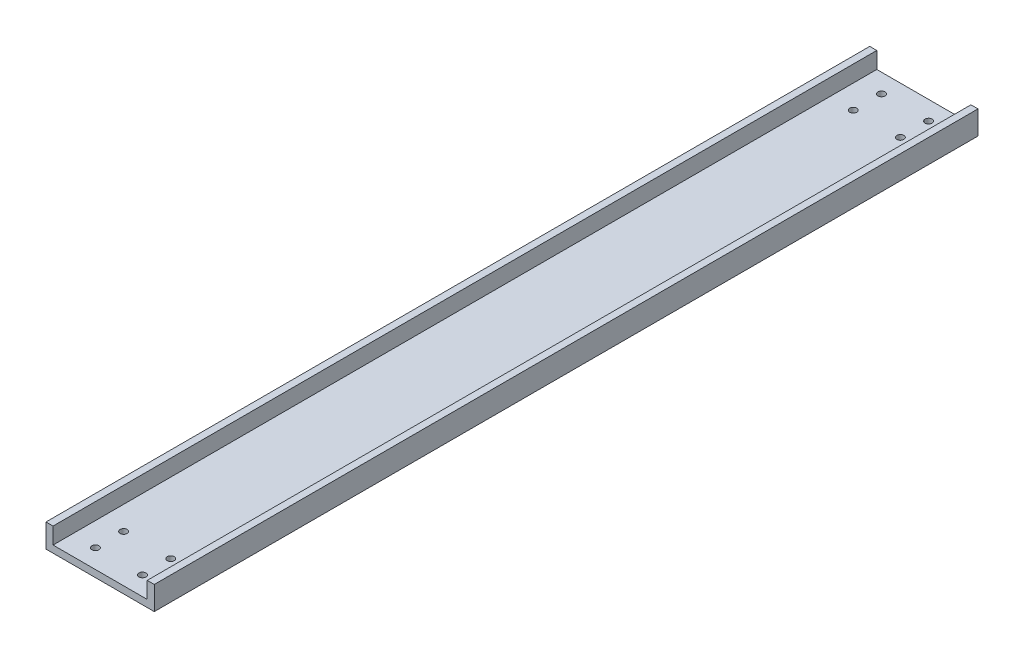
from build123d import *

# Parameters (mm, degrees)
BOSS_EXTRUDE1_DEPTH            = 350
F_3_0MM_DOWEL_HOLE1_AT_2_COUNT = 2
F_3_0MM_DOWEL_HOLE1_AT_2_PITCH = 20
F_3_0MM_DOWEL_HOLE1_AT_3_COUNT = 2
F_3_0MM_DOWEL_HOLE1_AT_3_PITCH = 23.323807579
F_3_0MM_DOWEL_HOLE1_AT_4_COUNT = 2
F_3_0MM_DOWEL_HOLE1_AT_4_PITCH = 12


with BuildPart() as part:
    # Sketch2 → Boss-Extrude1 (new body)
    with BuildSketch(Plane.XY):
        Polygon((0, 0), (0, 7), (-3, 7), (-3, -3), (43, -3), (43, 7), (40, 7), (40, 0), align=None)
    extrude(amount=BOSS_EXTRUDE1_DEPTH)

    # Sketch3 → Ø3.0mm Dowel Hole1 (revolve, cut)
    with BuildSketch(Plane(origin=(10, -3, 342), x_dir=(0, 0, -1), z_dir=(1, 0, 0))):
        Polygon((0, 0), (0, 15.901290929), (1.5, 15), (1.5, 0), align=None)
    f_3_0mm_dowel_hole1 = revolve(axis=Axis((10, -9.35, 342), (0, 1, 0)), mode=Mode.SUBTRACT)

    # Ø3.0mm Dowel Hole1 at 2: Ø3.0mm Dowel Hole1 ×2
    with Locations(*[(i * F_3_0MM_DOWEL_HOLE1_AT_2_PITCH, 0, 0) for i in range(1, F_3_0MM_DOWEL_HOLE1_AT_2_COUNT)]):
        add(f_3_0mm_dowel_hole1, mode=Mode.SUBTRACT)

    # Ø3.0mm Dowel Hole1 at 3: Ø3.0mm Dowel Hole1 ×2
    with Locations(*[Vector(0.857492926, 0, -0.514495755) * (i * F_3_0MM_DOWEL_HOLE1_AT_3_PITCH) for i in range(1, F_3_0MM_DOWEL_HOLE1_AT_3_COUNT)]):
        add(f_3_0mm_dowel_hole1, mode=Mode.SUBTRACT)

    # Ø3.0mm Dowel Hole1 at 4: Ø3.0mm Dowel Hole1 ×2
    with Locations(*[(0, 0, -i * F_3_0MM_DOWEL_HOLE1_AT_4_PITCH) for i in range(1, F_3_0MM_DOWEL_HOLE1_AT_4_COUNT)]):
        add(f_3_0mm_dowel_hole1, mode=Mode.SUBTRACT)

    # Mirror1: Ø3.0mm Dowel Hole1 across plane
    add(f_3_0mm_dowel_hole1.mirror(Plane.XY.offset(175)), mode=Mode.SUBTRACT)

    # Mirror1 copy 1 sketch → Mirror1 copy 1 (revolve, cut)
    with BuildSketch(Plane(origin=(30, -3, 8), x_dir=(0, 0, 1), z_dir=(1, 0, 0))):
        Polygon((0, 0), (0, -15.901290929), (1.5, -15), (1.5, 0), align=None)
    revolve(axis=Axis((30, -9.35, 8), (0, -1, 0)), mode=Mode.SUBTRACT)

    # Mirror1 copy 2 sketch → Mirror1 copy 2 (revolve, cut)
    with BuildSketch(Plane(origin=(30, -3, 20), x_dir=(0, 0, 1), z_dir=(1, 0, 0))):
        Polygon((0, 0), (0, -15.901290929), (1.5, -15), (1.5, 0), align=None)
    revolve(axis=Axis((30, -9.35, 20), (0, -1, 0)), mode=Mode.SUBTRACT)

    # Mirror1 copy 3 sketch → Mirror1 copy 3 (revolve, cut)
    with BuildSketch(Plane(origin=(10, -3, 20), x_dir=(0, 0, 1), z_dir=(1, 0, 0))):
        Polygon((0, 0), (0, -15.901290929), (1.5, -15), (1.5, 0), align=None)
    revolve(axis=Axis((10, -9.35, 20), (0, -1, 0)), mode=Mode.SUBTRACT)


solid = part.part
